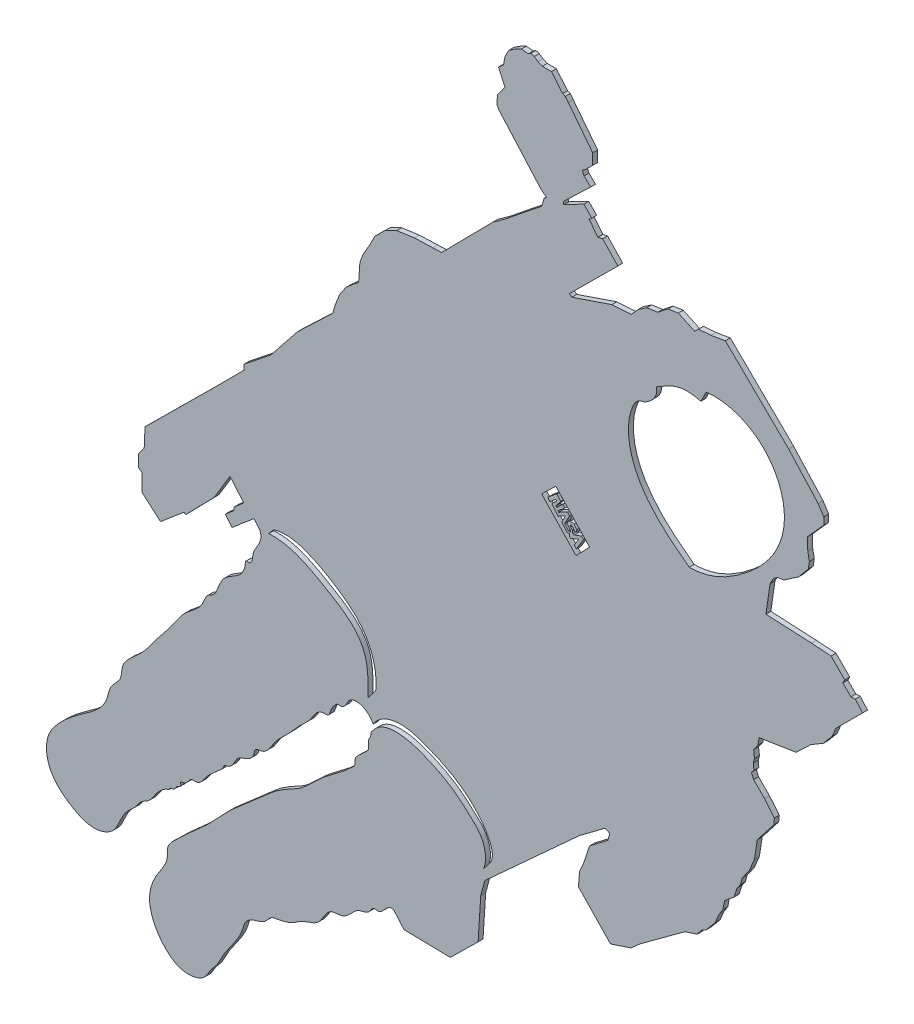
from build123d import *

# Parameters (mm, degrees)
BOSS_EXTRUDE1_DEPTH   = 1
BOSS_EXTRUDE1_2_DEPTH = 1


with BuildPart() as part:
    # Sketch1 → Boss-Extrude1 (new body)
    with BuildSketch(Plane.XY):
        with BuildLine():
            Line((78.874818105, 82.597395775), (77.921835909, 83.717291013))
            Line((77.921835909, 83.717291013), (73.476120642, 79.934180455))
            Line((73.476120642, 79.934180455), (72.077656548, 81.577582908))
            Line((72.077656548, 81.577582908), (73.849658319, 83.085479434))
            Line((73.849658319, 83.085479434), (73.849658319, 83.717291048))
            Line((73.849658319, 83.717291048), (75.848272981, 85.418025299))
            Line((75.848272981, 85.418025299), (73.04897407, 88.707616158))
            Line((73.04897407, 88.707616158), (69.831328191, 83.401385241))
            Line((69.831328191, 83.401385241), (68.294272949, 81.825735751))
            Line((68.294272949, 81.825735751), (64.022859461, 77.447070432))
            Line((64.022859461, 77.447070432), (63.715930565, 77.746481355))
            Line((63.715930565, 77.746481355), (58.939314116, 73.681788268))
            Line((58.939314116, 73.681788268), (55.17750791, 76.960844403))
            Line((55.17750791, 76.960844403), (55.17750791, 80.495676591))
            Line((55.17750791, 80.495676591), (54.488138591, 80.91370332))
            Line((54.488138591, 80.91370332), (54.488138591, 83.401385241))
            Line((54.488138591, 83.401385241), (55.627146968, 84.986707959))
            Line((55.627146968, 84.986707959), (55.793221269, 88.807852144))
            Line((55.793221269, 88.807852144), (69.395190162, 102.282504996))
            Line((69.395190162, 102.282504996), (75.890237058, 108.801688429))
            Line((75.890237058, 108.801688429), (75.939038817, 109.899728))
            Line((75.939038817, 109.899728), (81.331633152, 114.194282764))
            Line((81.331633152, 114.194282764), (86.733531557, 120.975114159))
            Line((86.733531557, 120.975114159), (93.889346409, 127.79474979))
            Line((93.889346409, 127.79474979), (94.468492452, 129.703627207))
            Line((94.468492452, 129.703627207), (95.407468443, 132.051067185))
            Line((95.407468443, 132.051067185), (96.646916752, 133.76000349))
            Line((96.646916752, 133.76000349), (98.224396417, 135.149687957))
            Line((98.224396417, 135.149687957), (99.163328112, 135.842533775))
            Line((99.163328112, 135.842533775), (99.421762503, 139.503687647))
            Line((99.421762503, 139.503687647), (100.06784848, 141.269655985))
            Line((100.06784848, 141.269655985), (101.381556634, 143.530956906))
            Line((101.381556634, 143.530956906), (102.479902796, 145.663040632))
            Line((102.479902796, 145.663040632), (104.633522721, 147.773588158))
            Line((104.633522721, 147.773588158), (106.894823642, 148.85039812))
            Line((106.894823642, 148.85039812), (110.491368916, 149.367266902))
            Line((110.491368916, 149.367266902), (114.260203785, 149.496484098))
            Line((114.260203785, 149.496484098), (116.026172123, 149.561092695))
            Line((116.026172123, 149.561092695), (126.446378341, 160.122863097))
            Line((126.446378341, 160.122863097), (129.026035224, 161.97097549))
            Line((129.026035224, 161.97097549), (134.069841965, 166.052223693))
            Line((134.069841965, 166.052223693), (136.341480116, 167.823331404))
            Line((136.341480116, 167.823331404), (136.842010556, 169.517434431))
            Line((136.842010556, 169.517434431), (137.342540996, 169.902457847))
            Line((137.342540996, 169.902457847), (136.225973091, 170.749509361))
            Line((136.225973091, 170.749509361), (127.716955612, 180.375094745))
            Line((127.716955612, 180.375094745), (127.227620711, 181.243004722))
            Line((127.227620711, 181.243004722), (127.379180673, 182.985944283))
            Line((127.379180673, 182.985944283), (128.894780291, 185.032003767))
            Line((128.894780291, 185.032003767), (127.568630625, 187.949533032))
            Line((127.568630625, 187.949533032), (128.591660368, 188.858892802))
            Line((128.591660368, 188.858892802), (128.894780291, 190.488162392))
            Line((128.894780291, 190.488162392), (129.690470091, 191.965872019))
            Line((129.690470091, 191.965872019), (131.168179718, 192.951011771))
            Line((131.168179718, 192.951011771), (132.229099451, 193.443581647))
            Line((132.229099451, 193.443581647), (133.668919088, 193.329911675))
            Line((133.668919088, 193.329911675), (134.161488964, 193.670921589))
            Line((134.161488964, 193.670921589), (134.843508792, 193.443581647))
            Line((134.843508792, 193.443581647), (135.639198591, 192.91312178))
            Line((135.639198591, 192.91312178), (136.472778381, 192.534221876))
            Line((136.472778381, 192.534221876), (138.329387913, 192.534221876))
            Line((138.329387913, 192.534221876), (140.60278734, 189.806142564))
            Line((140.60278734, 189.806142564), (141.133247206, 189.578802621))
            Line((141.133247206, 189.578802621), (141.739487054, 188.821002812))
            Line((141.739487054, 188.821002812), (146.70507726, 182.435056343))
            Line((146.70507726, 182.435056343), (146.70507726, 180.21810601))
            Line((146.70507726, 180.21810601), (145.048735057, 178.587245994))
            Line((145.048735057, 178.587245994), (144.56457349, 178.357906304))
            Line((144.56457349, 178.357906304), (144.946806306, 177.491511921))
            Line((144.946806306, 177.491511921), (146.271880068, 176.191920346))
            Line((146.271880068, 176.191920346), (140.818691891, 170.968071859))
            Line((140.818691891, 170.968071859), (140.818691891, 170.381981541))
            Line((140.818691891, 170.381981541), (144.921324118, 172.522485311))
            Line((144.921324118, 172.522485311), (146.50472075, 170.843145049))
            Line((146.50472075, 170.843145049), (145.971836359, 170.37295294))
            Line((145.971836359, 170.37295294), (147.758566375, 168.116030814))
            Line((147.758566375, 168.116030814), (148.730296735, 168.335453798))
            Line((148.730296735, 168.335453798), (151.802218518, 165.075455172))
            Line((151.802218518, 165.075455172), (141.959530357, 155.295459292))
            Line((141.959530357, 155.295459292), (142.461068607, 154.919305604))
            Line((142.461068607, 154.919305604), (150.579719033, 157.67776598))
            Line((150.579719033, 157.67776598), (154.529332753, 157.928535106))
            Line((154.529332753, 157.928535106), (155.939909082, 159.495842138))
            Line((155.939909082, 159.495842138), (157.695292958, 160.686995482))
            Line((157.695292958, 160.686995482), (159.920868944, 161.000456888))
            Line((159.920868944, 161.000456888), (162.021060366, 162.630456202))
            Line((162.021060366, 162.630456202), (164.089905649, 162.943917608))
            Line((164.089905649, 162.943917608), (167.412596557, 161.407956717))
            Line((167.412596557, 161.407956717), (168.196250073, 162.160264092))
            Line((168.196250073, 162.160264092), (170.735287464, 162.348340936))
            Line((170.735287464, 162.348340936), (173.650478544, 162.849879186))
            Line((173.650478544, 162.849879186), (186.479794269, 150.266978841))
            Line((186.479794269, 150.266978841), (192.47104375, 143.650137044))
            Line((192.47104375, 143.650137044), (193.625983409, 141.86960507))
            Line((193.625983409, 141.86960507), (193.625983409, 140.401869253))
            Line((193.625983409, 140.401869253), (190.310503443, 136.707688285))
            Line((190.310503443, 136.707688285), (190.377928144, 134.229830514))
            Line((190.377928144, 134.229830514), (190.698195475, 132.544212982))
            Line((190.698195475, 132.544212982), (190.495921371, 131.128294256))
            Line((190.495921371, 131.128294256), (188.490036509, 128.734717361))
            Line((188.490036509, 128.734717361), (185.495893463, 126.703259833))
            Line((185.495893463, 126.703259833), (184.271692392, 126.524108457))
            Line((184.271692392, 126.524108457), (183.465511199, 125.986654328))
            Line((183.465511199, 125.986654328), (182.719047131, 124.672877569))
            Line((182.719047131, 124.672877569), (181.883007375, 118.880316405))
            Line((181.883007375, 118.880316405), (191.114529855, 118.413847313))
            Line((191.114529855, 118.413847313), (195.101292498, 118.144471458))
            Line((195.101292498, 118.144471458), (197.902801383, 115.342962574))
            Line((197.902801383, 115.342962574), (197.498737601, 114.615647767))
            Line((197.498737601, 114.615647767), (199.141930312, 112.972455056))
            Line((199.141930312, 112.972455056), (200.030870632, 113.026330227))
            Line((200.030870632, 113.026330227), (201.51243783, 111.329262345))
            Line((201.51243783, 111.329262345), (196.076466872, 105.902535437))
            Line((196.076466872, 105.902535437), (195.318059025, 104.112692917))
            Line((195.318059025, 104.112692917), (193.558552819, 102.019487259))
            Line((193.558552819, 102.019487259), (191.010302452, 100.502671564))
            Line((191.010302452, 100.502671564), (188.007007377, 97.651058059))
            Line((188.007007377, 97.651058059), (180.483601532, 96.467941817))
            Line((180.483601532, 96.467941817), (180.25962246, 95.020826837))
            Line((180.25962246, 95.020826837), (179.378947133, 93.825624608))
            Line((179.378947133, 93.825624608), (179.567663274, 92.315895476))
            Line((179.567663274, 92.315895476), (179.316041753, 91.43522015))
            Line((179.316041753, 91.43522015), (179.441852513, 90.17711254))
            Line((179.441852513, 90.17711254), (178.93860947, 89.610964116))
            Line((178.93860947, 89.610964116), (179.378947133, 88.541572647))
            Line((179.378947133, 88.541572647), (181.58063545, 86.33988433))
            Line((181.58063545, 86.33988433), (183.593607625, 83.886574492))
            Line((183.593607625, 83.886574492), (183.467796864, 82.628466882))
            Line((183.467796864, 82.628466882), (180.133811699, 78.350901009))
            Line((180.133811699, 78.350901009), (179.552454744, 74.633764184))
            Line((179.552454744, 74.633764184), (178.528992602, 72.148213268))
            Line((178.528992602, 72.148213268), (177.066903828, 70.101288984))
            Line((177.066903828, 70.101288984), (176.701381635, 68.712304648))
            Line((176.701381635, 68.712304648), (176.043441686, 67.835051384))
            Line((176.043441686, 67.835051384), (175.385501738, 65.861231539))
            Line((175.385501738, 65.861231539), (173.484786332, 64.326038326))
            Line((173.484786332, 64.326038326), (173.119264138, 62.498427358))
            Line((173.119264138, 62.498427358), (172.388219751, 61.401860778))
            Line((172.388219751, 61.401860778), (171.584070925, 59.501145371))
            Line((171.584070925, 59.501145371), (169.756459958, 57.30801221))
            Line((169.756459958, 57.30801221), (168.806102254, 56.796281139))
            Line((168.806102254, 56.796281139), (167.92884899, 55.62661012))
            Line((167.92884899, 55.62661012), (165.443298074, 54.822461294))
            Line((165.443298074, 54.822461294), (156.378347674, 48.169957372))
            Line((156.378347674, 48.169957372), (154.477632268, 46.488555281))
            Line((154.477632268, 46.488555281), (150.310679262, 45.099570946))
            Line((150.310679262, 45.099570946), (143.804384217, 51.898283746))
            Line((143.804384217, 51.898283746), (144.023697533, 54.676252417))
            Line((144.023697533, 54.676252417), (144.827846359, 56.503863384))
            Line((144.827846359, 56.503863384), (146.070621817, 60.232189758))
            Line((146.070621817, 60.232189758), (149.798948191, 63.083262868))
            Line((149.798948191, 63.083262868), (150.164470384, 64.472247203))
            Line((150.164470384, 64.472247203), (149.214112681, 64.910873836))
            Line((149.214112681, 64.910873836), (143.950593094, 60.963234145))
            Line((143.950593094, 60.963234145), (124.797230153, 43.491273294))
            Line((124.797230153, 43.491273294), (123.968267227, 40.446403438))
            Line((123.968267227, 40.446403438), (123.430862227, 32.027058444))
            Line((123.430862227, 32.027058444), (117.788109731, 26.473873448))
            Line((117.788109731, 26.473873448), (108.383522238, 26.653008448))
            Line((108.383522238, 26.653008448), (106.349245501, 29.025135929))
            add(Edge.make_bspline(
                [(101.705517208, 58.05468694), (101.687965859, 57.791268087), (101.634069992, 57.15284096), (100.892196015, 56.186617895), (101.505878486, 54.746780939), (100.46043618, 54.022628267), (99.608427638, 52.988094726), (98.213960783, 52.140586504), (98.552006244, 50.524669869), (97.760747102, 49.912017226), (95.703807882, 47.862171661), (91.45345751, 45.335782942), (88.353353851, 41.463670684), (84.920367725, 39.652238686), (82.302849642, 38.213371571), (78.13974329, 34.149880923), (73.490778697, 30.739053064), (68.298464983, 24.652917922), (63.839385107, 21.291528975), (60.095207851, 17.350767292), (60.456464317, 15.211540463), (59.643067416, 13.290160037), (57.733933165, 10.777172249), (55.810806644, 5.646851186), (58.600837913, -0.110269251), (63.259880475, -3.638393735), (67.893177306, -2.753849879), (69.003061354, -0.002152754), (70.401284149, 1.282241862), (71.238229968, 3.168481448), (73.102565173, 6.16324336), (75.345334113, 8.837584348), (76.067662858, 12.14719911), (77.921529128, 13.263262118), (80.207198188, 13.562616078), (81.146011775, 15.374533418), (83.404843085, 15.760768369), (85.459115517, 16.153130999), (87.892392752, 18.205669756), (91.494221903, 18.499265944), (92.65197536, 22.762425814), (95.376656166, 22.56399258), (97.380228229, 23.533211413), (98.63053029, 25.709045742), (101.267666529, 25.699960769), (101.921234446, 27.558645186), (104.285784983, 26.848277372), (104.759436667, 29.650302486), (106.349245501, 29.025135929)],
                knots=[0.011329231, 0.011329231, 0.011329231, 0.011329231, 0.016894419, 0.02483974, 0.035495902, 0.043516767, 0.048499196, 0.065057568, 0.072122281, 0.079292408, 0.084287783, 0.135046617, 0.182467091, 0.186965298, 0.217656866, 0.245611441, 0.310319165, 0.340269682, 0.414271386, 0.435623651, 0.444984401, 0.458336294, 0.478494478, 0.51290296, 0.568690799, 0.599771142, 0.633985202, 0.648411731, 0.660540577, 0.673773602, 0.691788863, 0.735932959, 0.746508658, 0.761276917, 0.778181623, 0.793699605, 0.798299289, 0.8260297, 0.8368649, 0.865170754, 0.894835376, 0.908373089, 0.91784068, 0.941489892, 0.95606946, 0.966939047, 0.973607834, 1, 1, 1, 1], degree=3))
            Line((101.705517208, 58.05468694), (102.32207622, 58.832199172))
            add(Edge.make_bspline(
                [(102.32207622, 58.832199172), (103.738377925, 60.515324015), (108.018162808, 61.035558119), (113.385738899, 59.073638742), (117.941582985, 56.750120267), (121.377420733, 53.815788559), (124.856532223, 50.591980657), (125.185899894, 47.050128826), (124.547102539, 45.468358805)],
                knots=[0, 0, 0, 0, 0.19527341, 0.392515442, 0.55163158, 0.689957975, 0.834125172, 1, 1, 1, 1], degree=3))
            Line((124.547102539, 45.468358805), (125.950057666, 47.247716527))
            add(Edge.make_bspline(
                [(102.37356785, 60.045404758), (103.772168939, 61.946150271), (107.798482831, 63.001474626), (113.467729471, 61.128342998), (118.60793204, 58.808557267), (122.894993467, 55.390805974), (125.698600762, 51.582550049), (126.736736138, 48.729265536), (125.950057666, 47.247716527)],
                knots=[0, 0, 0, 0, 0.209907719, 0.351243424, 0.554015517, 0.737878293, 0.855088702, 1, 1, 1, 1], degree=3))
            Line((102.37356785, 60.045404758), (102.145564779, 59.695798089))
            add(Edge.make_bspline(
                [(102.145564779, 59.695798089), (101.898860262, 60.139825008), (100.973624475, 61.329647305), (99.059761875, 62.261513307), (97.183757276, 61.59647386), (96.697587803, 60.341002755), (95.86916958, 59.346462026), (94.819091767, 59.665038043), (94.208202053, 58.922371052), (93.50891214, 58.126129288), (93.276668483, 56.460533644), (91.5825358, 56.722110422), (90.341375279, 55.742182391), (89.339995803, 53.80773046), (87.187733156, 52.099886247), (85.045302647, 49.338169081), (82.809732403, 47.522521838), (81.323061325, 45.19319043), (80.23382471, 43.470707398), (78.018438165, 43.495721314), (77.960649475, 41.979406042), (76.898720261, 40.763749617), (75.520200347, 40.482572285), (74.427949755, 39.807515365), (73.891878723, 38.606841331), (73.052051925, 37.485354447), (71.813092514, 37.354657498), (71.648316116, 36.646930458), (71.062047911, 36.057300169), (70.199479412, 35.35473135), (69.12093, 34.406258667), (67.870736806, 33.145443335), (66.895998461, 31.239825466), (65.261477758, 31.667508871), (64.501702558, 30.774124449), (64.023574116, 30.02532044), (62.842816877, 30.05141008), (63.166821353, 29.412231859), (62.803487027, 28.906507618), (62.18612649, 28.838990284), (61.942501535, 28.143619198), (61.424717134, 27.84832717), (60.829100073, 27.874829437), (60.792860952, 27.409478427), (60.23323103, 27.312536256), (59.327452487, 26.792560667), (57.907679359, 25.465261851), (56.906584482, 23.357438537), (54.785383936, 22.562090665), (54.094622708, 21.089480998), (52.598789764, 19.896800831), (50.902276395, 17.923017), (49.939359067, 14.331737769), (45.445493374, 12.414235297), (40.410926883, 14.52087862), (35.91310785, 18.407356834), (35.414251511, 24.460292127), (38.534070985, 28.359319079), (42.827346877, 32.010608384), (48.017962861, 34.958898551), (48.551080331, 39.940422686), (51.188043675, 41.694552718), (50.92549878, 44.608041327), (52.889436044, 46.787674312), (55.640890841, 48.969640573), (58.27308301, 52.990529361), (61.376065713, 56.454958993), (63.896108072, 60.655929433), (67.440912835, 62.378799685), (68.16761229, 65.606796974), (69.944716304, 66.170912385), (70.694130231, 68.153260744), (71.784562743, 70.767484864), (75.110091508, 71.90088701), (76.132702356, 73.986659463), (76.201530327, 75.6228864), (77.240550418, 75.253555618), (77.668800135, 76.495673515), (77.698906259, 78.073380861), (79.070640137, 79.627914816), (79.477749342, 81.513236171), (79.080387101, 82.355821756), (78.874818105, 82.597395775)],
                knots=[0.001138401, 0.001138401, 0.001138401, 0.001138401, 0.010413774, 0.026528389, 0.03554051, 0.041020382, 0.050262636, 0.054207134, 0.057843782, 0.065502612, 0.074322778, 0.080795898, 0.090932717, 0.100190905, 0.119012456, 0.138174176, 0.161941775, 0.168568666, 0.187357903, 0.194117655, 0.200813332, 0.209543426, 0.221101956, 0.224841011, 0.231610095, 0.24380875, 0.247524041, 0.251053447, 0.255094287, 0.262119635, 0.270698422, 0.280177697, 0.294451848, 0.301848369, 0.304183753, 0.314386581, 0.316834577, 0.320142402, 0.322750185, 0.326827869, 0.32963447, 0.334669033, 0.336728806, 0.338352404, 0.341313163, 0.345222905, 0.357329712, 0.374650137, 0.384239226, 0.394869249, 0.401685001, 0.417800236, 0.440048093, 0.463685125, 0.492886077, 0.532003809, 0.562826644, 0.588598208, 0.616137898, 0.664706828, 0.681807736, 0.698843574, 0.71408089, 0.727881387, 0.748106737, 0.776431848, 0.811301714, 0.830324669, 0.861682205, 0.875474622, 0.881643469, 0.892014927, 0.910318557, 0.930005603, 0.948075407, 0.950228118, 0.95468902, 0.96058215, 0.968643623, 0.983683629, 0.994778909, 1, 1, 1, 1], degree=3))
        make_face()
        with BuildLine():
            Line((168.673415925, 149.726393073), (169.756459958, 151.885990943))
            add(Edge.make_bspline(
                [(169.756459958, 151.885990943), (173.759872373, 152.362698173), (180.352496535, 150.195939706), (185.278562123, 142.807447819), (186.064073395, 136.072906835), (183.433697837, 129.350887113), (177.054134682, 122.885422868), (170.628930993, 119.334313785), (166.307660776, 119.356703185)],
                knots=[0, 0, 0, 0, 0.229405478, 0.358459798, 0.488259908, 0.600167245, 0.758426692, 1, 1, 1, 1], degree=3))
            add(Edge.make_bspline(
                [(166.307660776, 119.356703185), (162.672190953, 122.01064853), (157.449032793, 126.224030667), (153.774974876, 134.49896678), (153.780886537, 140.311241186), (155.675000288, 143.663094875), (157.045335105, 143.809242958)],
                knots=[0, 0, 0, 0, 0.454386361, 0.635638113, 0.885915141, 1, 1, 1, 1], degree=3))
            add(Edge.make_bspline(
                [(157.045335105, 143.809242958), (158.468048496, 144.424329631), (160.078691828, 146.021380991), (159.606531402, 147.735067967)],
                knots=[0, 0, 0, 0, 1, 1, 1, 1], degree=3))
            add(Edge.make_bspline(
                [(159.606531402, 147.735067967), (161.311277689, 148.790428265), (164.328543801, 150.603280724), (167.587937937, 149.95752502), (168.673415925, 149.726393073)],
                knots=[0, 0, 0, 0, 0.648467817, 1, 1, 1, 1], degree=3))
        make_face(mode=Mode.SUBTRACT)
        with BuildLine():
            Line((101.074100508, 63.758171988), (102.638789687, 65.827599612))
            add(Edge.make_bspline(
                [(81.944513447, 83.745814405), (84.51244536, 84.598382862), (89.386932306, 83.230145098), (95.340757144, 79.771469484), (101.41068041, 74.821875152), (102.998278649, 69.138761928), (102.638789687, 65.827599612)],
                knots=[0, 0, 0, 0, 0.252253129, 0.472596442, 0.674625677, 1, 1, 1, 1], degree=3))
            Line((81.944513447, 83.745814405), (80.935036557, 82.597395775))
            add(Edge.make_bspline(
                [(80.935036557, 82.597395775), (85.464037728, 82.874171594), (91.246803679, 79.579724214), (97.810405469, 75.526819411), (101.317240935, 70.506007022), (101.059282603, 66.298466728), (101.074100508, 63.758171988)],
                knots=[0, 0, 0, 0, 0.42464333, 0.625216193, 0.742801858, 1, 1, 1, 1], degree=3))
        make_face(mode=Mode.SUBTRACT)
        Polygon((139.205313086, 120.039557299), (146.070621817, 112.769633903), (143.302452044, 109.899728), (136.341480116, 117.270952611), align=None, mode=Mode.SUBTRACT)
    extrude(amount=BOSS_EXTRUDE1_DEPTH)


with BuildPart() as body_2:
    # Sketch1 → Boss-Extrude1 2 (new body)
    with BuildSketch(Plane.XY):
        Polygon((139.197988563, 118.664389307), (137.565046393, 117.279879718), (138.01653346, 116.747379058), (139.205313086, 117.755300111), (139.389536429, 117.53802024), (138.388964217, 116.570719093), (139.709401523, 115.013346159), (141.133247206, 115.792032626), (140.421324365, 114.311321944), (141.460804825, 113.085319978), (141.959530357, 113.085319978), (141.959530357, 112.59004521), (142.192097118, 112.351097555), (143.851688717, 113.052574416), (142.962010746, 111.581183927), (143.38974054, 111.102126558), (144.826912646, 113.497413401), (144.399182852, 113.890924811), (142.979119938, 113.377649059), (142.671154487, 113.394758251), (142.60271772, 114.010689154), (142.192097118, 114.421309755), (142.260533885, 114.814821165), (142.636936103, 114.592401673), (143.09888428, 113.97647077), (143.423958923, 114.062016729), (143.475286498, 114.541074098), (142.876464787, 115.242550959), (142.157878734, 115.379424493), (141.678821366, 115.122786617), (141.473511065, 114.592401673), (142.192097118, 113.771160469), (142.192097118, 113.497413401), (141.747258133, 113.514522593), (141.028672079, 114.421309755), (141.986786817, 116.217774888), (141.610384599, 116.696832257), (139.779701082, 115.755826711), (139.677045932, 115.995355395), (141.028672079, 117.107452859), (140.635160669, 117.552291844), (139.334862097, 116.371757614), (139.26642533, 116.645504682), (140.207430876, 117.877366487), (139.437517248, 118.818372033), align=None)
    extrude(amount=BOSS_EXTRUDE1_2_DEPTH)


solid = Compound([part.part, body_2.part])
